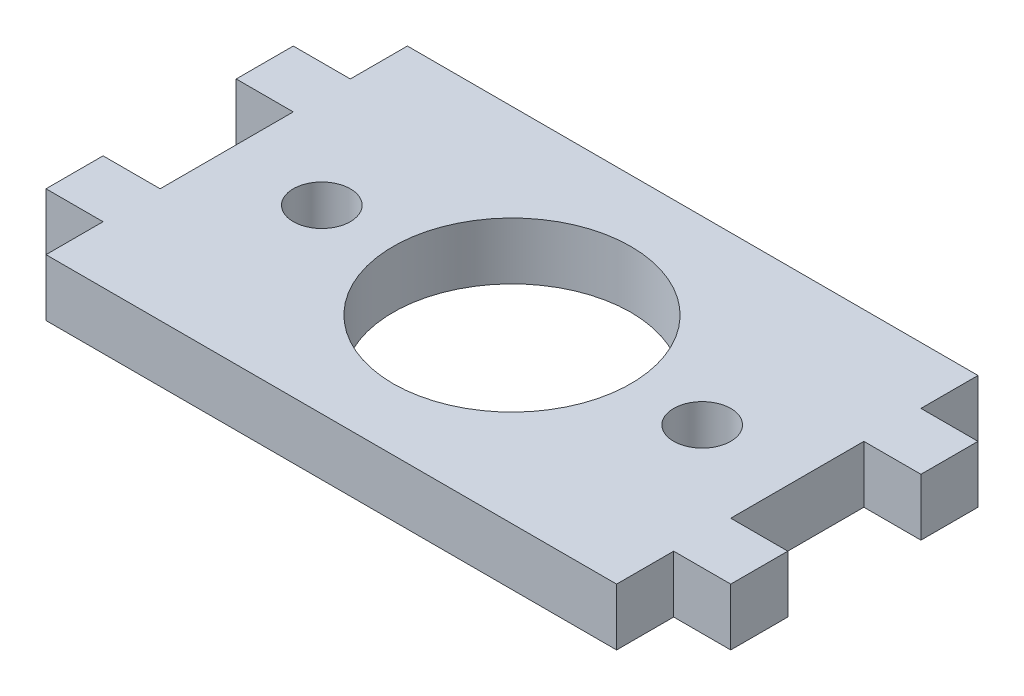
from build123d import *

# Parameters (mm, degrees)
SKETCH1_R           = 6.25
SKETCH1_R_2         = 1.5
BOSS_EXTRUDE1_DEPTH = 3


with BuildPart() as part:
    # Sketch1 → Boss-Extrude1 (new body)
    with BuildSketch(Plane(origin=(0, 0, 0), x_dir=(1, 0, 0), z_dir=(0, 1, 0))):
        Polygon((-42.867412192, 7), (-42.867412192, 10), (-39.867412192, 10), (-39.867412192, 13), (-9.867412192, 13), (-9.867412192, 10), (-6.867412192, 10), (-6.867412192, 7), (-9.867412192, 7), (-9.867412192, 0), (-6.867412192, 0), (-6.867412192, -3), (-9.867412192, -3), (-9.867412192, -6), (-39.867412192, -6), (-39.867412192, -3), (-42.867412192, -3), (-42.867412192, 0), (-39.867412192, 0), (-39.867412192, 7), align=None)
        with Locations((-24.867412192, 3.5)):
            Circle(SKETCH1_R, mode=Mode.SUBTRACT)
        with Locations((-34.867412192, 3.5)):
            Circle(SKETCH1_R_2, mode=Mode.SUBTRACT)
        with Locations((-14.867412192, 3.5)):
            Circle(SKETCH1_R_2, mode=Mode.SUBTRACT)
    extrude(amount=BOSS_EXTRUDE1_DEPTH)


solid = part.part
